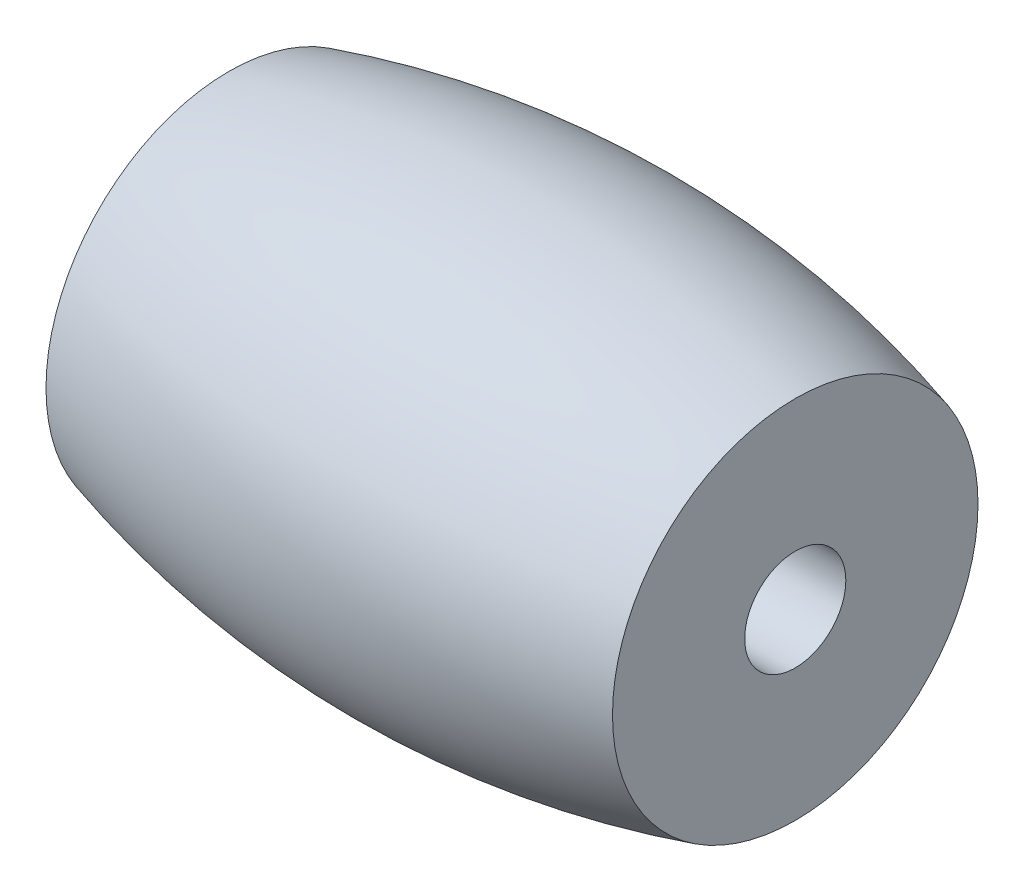
from build123d import *

# Parameters (mm, degrees)
SKETCH_2_R          = 1.25
CUT_EXTRUDE_1_DEPTH = 18


with BuildPart() as part:
    # 草图1 → 旋转1 (revolve)
    with BuildSketch(Plane.XY):
        with BuildLine():
            Line((7, 19.9), (-7, 19.9))
            Line((-7, 19.9), (-7, 15.383612061))
            ThreePointArc((-7, 15.383612061), (0, 14.4), (7, 15.383612061))
            Line((7, 15.383612061), (7, 19.9))
        make_face()
    revolve(axis=Axis((7, 19.9, 0), (-1, 0, 0)))

    # 草图2 → 切除-拉伸1 (cut)
    with BuildSketch(Plane(origin=(7, 0, 0), x_dir=(0, 0, -1), z_dir=(1, 0, 0))):
        with Locations((0, 19.9)):
            Circle(SKETCH_2_R)
    extrude(amount=-CUT_EXTRUDE_1_DEPTH, mode=Mode.SUBTRACT)


solid = part.part
